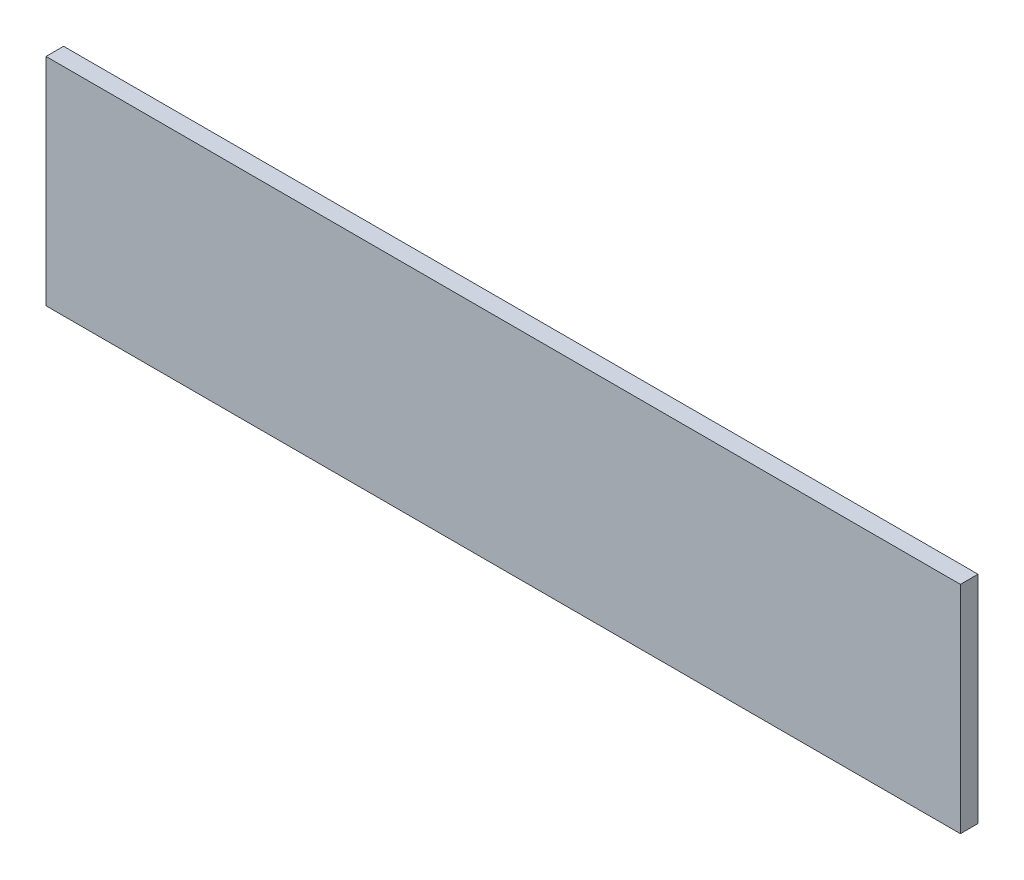
from build123d import *

# Parameters (mm, degrees)
CROQUIS1_W              = 260
CROQUIS1_H              = 61.406944489
SALIENTE_EXTRUIR1_DEPTH = 5


with BuildPart() as part:
    # Croquis1 → Saliente-Extruir1 (new body)
    with BuildSketch(Plane.XY):
        with Locations((-0.184670885, -2.751631701)):
            Rectangle(CROQUIS1_W, CROQUIS1_H)
    extrude(amount=SALIENTE_EXTRUIR1_DEPTH)


solid = part.part
